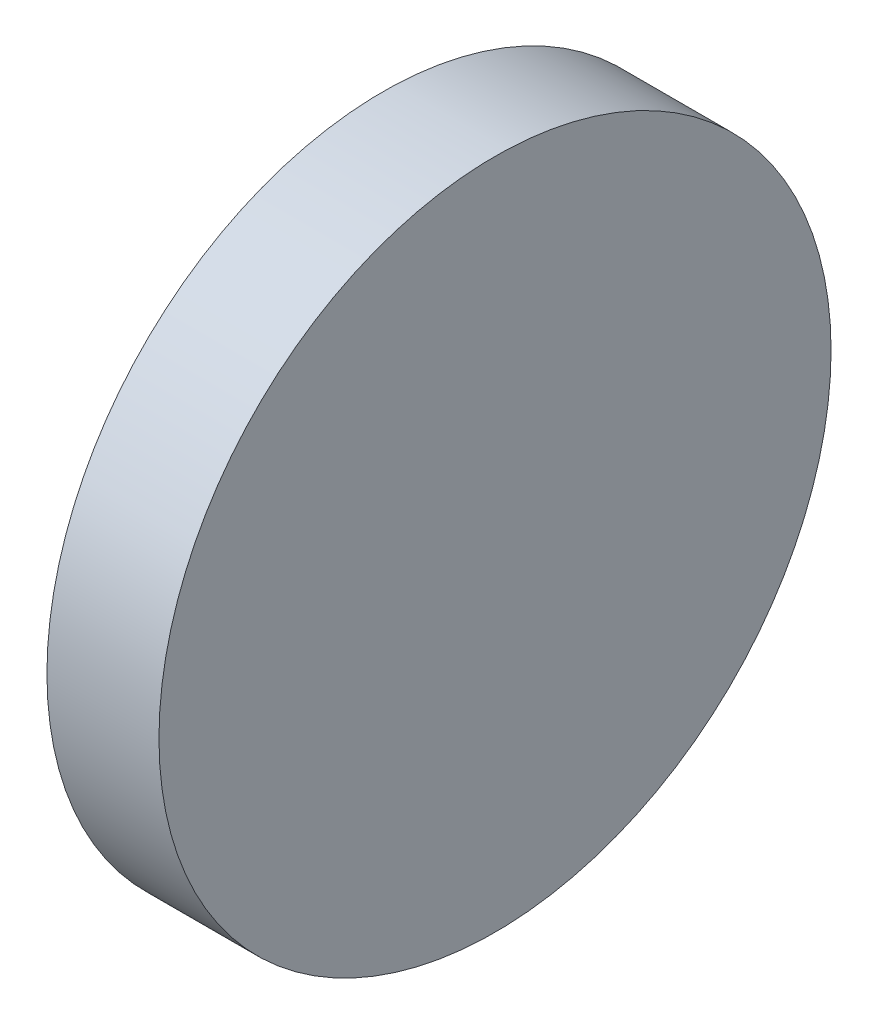
from build123d import *

# Parameters (mm, degrees)
SKETCH1_R           = 3
BOSS_EXTRUDE1_DEPTH = 1


with BuildPart() as part:
    # Sketch1 → Boss-Extrude1 (new body)
    with BuildSketch(Plane(origin=(0, 0, 0), x_dir=(0, 0, -1), z_dir=(1, 0, 0))):
        Circle(SKETCH1_R)
    extrude(amount=BOSS_EXTRUDE1_DEPTH)


solid = part.part
